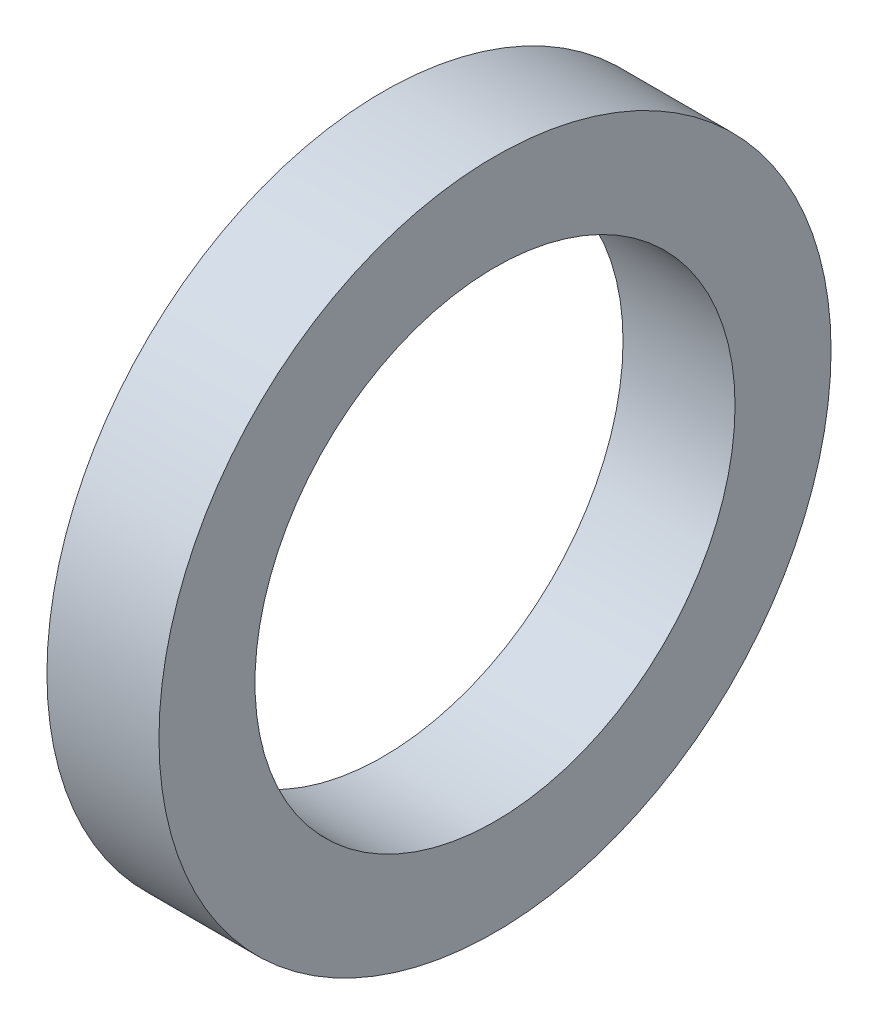
from build123d import *

# Parameters (mm, degrees)
SKETCH1_R           = 21
SKETCH1_R_2         = 15
BOSS_EXTRUDE1_DEPTH = 3.5


with BuildPart() as part:
    # Sketch1 → Boss-Extrude1 (new, symmetric)
    with BuildSketch(Plane(origin=(0, 0, 0), x_dir=(0, 0, -1), z_dir=(1, 0, 0))):
        Circle(SKETCH1_R)
        Circle(SKETCH1_R_2, mode=Mode.SUBTRACT)
    extrude(amount=BOSS_EXTRUDE1_DEPTH, both=True)


solid = part.part
